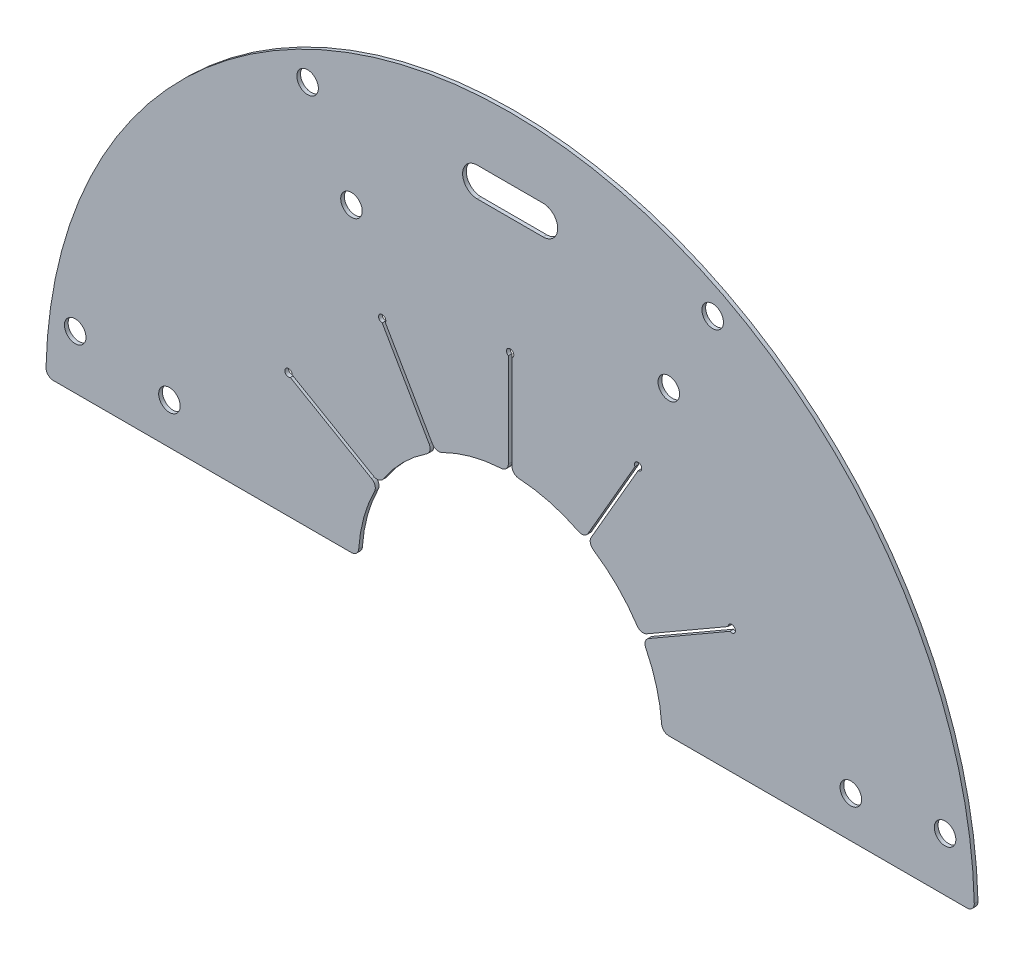
from build123d import *

# Parameters (mm, degrees)
BOSS_EXTRUDE1_DEPTH            = 0.508
CUT_EXTRUDE1_DEPTH             = 1.508
CIRPATTERN1_COUNT              = 5
CIRPATTERN1_ANGLE              = 120
FILLET1_R                      = 1
F_4_CLEARANCE_HOLE1_AT_2_COUNT = 2
F_4_CLEARANCE_HOLE1_AT_2_PITCH = 13
CIRPATTERN2_COUNT              = 4
CIRPATTERN2_ANGLE              = 165
CUT_EXTRUDE2_DEPTH             = 1.508


with BuildPart() as part:
    # Sketch1 → Boss-Extrude1 (new body)
    with BuildSketch(Plane.XY):
        with BuildLine():
            Line((63.498031466, 0.5), (20.758479237, 0.5))
            ThreePointArc((20.758479237, 0.5), (0, 20.7645), (-20.758479237, 0.5))
            Line((-20.758479237, 0.5), (-63.498031466, 0.5))
            ThreePointArc((-63.498031466, 0.5), (0, 63.5), (63.498031466, 0.5))
        make_face()
    extrude(amount=BOSS_EXTRUDE1_DEPTH)

    # Sketch2 → Cut-Extrude1 (cut, through all)
    with BuildSketch(Plane(origin=(0, 0, 0), x_dir=(-1, 0, 0), z_dir=(0, 0, -1))):
        with BuildLine():
            Line((29.810889132, 17.5), (17.856281105, 10.598003837))
            Line((17.856281105, 10.598003837), (18.106281105, 10.164991136))
            Line((18.106281105, 10.164991136), (30.060889132, 17.066987298))
            ThreePointArc((30.060889132, 17.066987298), (30.743901834, 17.75), (29.810889132, 17.5))
        make_face()
    cut_extrude1 = extrude(amount=-CUT_EXTRUDE1_DEPTH, mode=Mode.SUBTRACT)

    # CirPattern1: Cut-Extrude1 ×5 about axis
    cirpattern1_axis = Axis((0, 0, 0), (0, 0, -1))
    for i in range(1, CIRPATTERN1_COUNT):
        add(cut_extrude1.rotate(cirpattern1_axis, i * CIRPATTERN1_ANGLE / (CIRPATTERN1_COUNT - 1)), mode=Mode.SUBTRACT)

    # Fillet1
    fillet1_edges = [part.edges().sort_by_distance(p)[0] for p in [
        (-18.106281105, 10.164991136, 0.254),
        (-17.856281105, 10.598003837, 0.254),
        (-10.598003837, 17.856281105, 0.254),
        (-10.164991136, 18.106281105, 0.254),
        (-0.25, 20.762994973, 0.254),
        (0.25, 20.762994973, 0.254),
        (10.164991136, 18.106281105, 0.254),
        (10.598003837, 17.856281105, 0.254),
        (18.106281105, 10.164991136, 0.254),
        (17.856281105, 10.598003837, 0.254),
        (63.498031466, 0.5, 0.254),
        (20.758479237, 0.5, 0.254),
        (-63.498031466, 0.5, 0.254),
        (-20.758479237, 0.5, 0.254),
    ]]
    fillet(fillet1_edges, radius=FILLET1_R)

    # Sketch3 → #4 Clearance Hole1 (revolve, cut)
    with BuildSketch(Plane(origin=(59.486691682, 7.831571533, 0), x_dir=(0, 1, 0), z_dir=(1, 0, 0))):
        Polygon((0, 0), (0, 136.775187864), (1.4732, 135.89), (1.4732, 0), align=None)
    f_4_clearance_hole1 = revolve(axis=Axis((59.486691682, 7.831571533, -6.35), (0, 0, 1)), mode=Mode.SUBTRACT)

    # #4 Clearance Hole1 at 2: #4 Clearance Hole1 ×2
    with Locations(*[Vector(-0.991444861, -0.130526192, 0) * (i * F_4_CLEARANCE_HOLE1_AT_2_PITCH) for i in range(1, F_4_CLEARANCE_HOLE1_AT_2_COUNT)]):
        add(f_4_clearance_hole1, mode=Mode.SUBTRACT)

    # CirPattern2: #4 Clearance Hole1 ×4 about axis
    cirpattern2_axis = Axis((0, 0, 0), (0, 0, 1))
    for i in range(1, CIRPATTERN2_COUNT):
        add(f_4_clearance_hole1.rotate(cirpattern2_axis, i * CIRPATTERN2_ANGLE / (CIRPATTERN2_COUNT - 1)), mode=Mode.SUBTRACT)

    # CirPattern2 copy 1 sketch → CirPattern2 copy 1 (revolve, cut)
    with BuildSketch(Plane(origin=(21.702184822, 41.689509159, 0), x_dir=(-0.819152044, 0.573576436, 0), z_dir=(0.573576436, 0.819152044, 0))):
        Polygon((0, 0), (0, 136.775187864), (1.4732, 135.89), (1.4732, 0), align=None)
    revolve(axis=Axis((21.702184822, 41.689509159, -6.35), (0, 0, 1)), mode=Mode.SUBTRACT)

    # CirPattern2 copy 2 sketch → CirPattern2 copy 2 (revolve, cut)
    with BuildSketch(Plane(origin=(-21.702184822, 41.689509159, 0), x_dir=(-0.939692621, -0.342020143, 0), z_dir=(-0.342020143, 0.939692621, 0))):
        Polygon((0, 0), (0, 136.775187864), (1.4732, 135.89), (1.4732, 0), align=None)
    revolve(axis=Axis((-21.702184822, 41.689509159, -6.35), (0, 0, 1)), mode=Mode.SUBTRACT)

    # CirPattern2 copy 3 sketch → CirPattern2 copy 3 (revolve, cut)
    with BuildSketch(Plane(origin=(-46.597908485, 6.134731034, 0), x_dir=(-0.258819045, -0.965925826, 0), z_dir=(-0.965925826, 0.258819045, 0))):
        Polygon((0, 0), (0, 136.775187864), (1.4732, 135.89), (1.4732, 0), align=None)
    revolve(axis=Axis((-46.597908485, 6.134731034, -6.35), (0, 0, 1)), mode=Mode.SUBTRACT)

    # Sketch5 → Cut-Extrude2 (cut, through all)
    with BuildSketch(Plane(origin=(0, 0, 0), x_dir=(-1, 0, 0), z_dir=(0, 0, -1))):
        with BuildLine():
            Line((-4.5, 55), (4.5, 55))
            ThreePointArc((4.5, 55), (6.5, 53), (4.5, 51))
            Line((4.5, 51), (-4.5, 51))
            ThreePointArc((-4.5, 51), (-6.5, 53), (-4.5, 55))
        make_face()
    extrude(amount=-CUT_EXTRUDE2_DEPTH, mode=Mode.SUBTRACT)


solid = part.part
